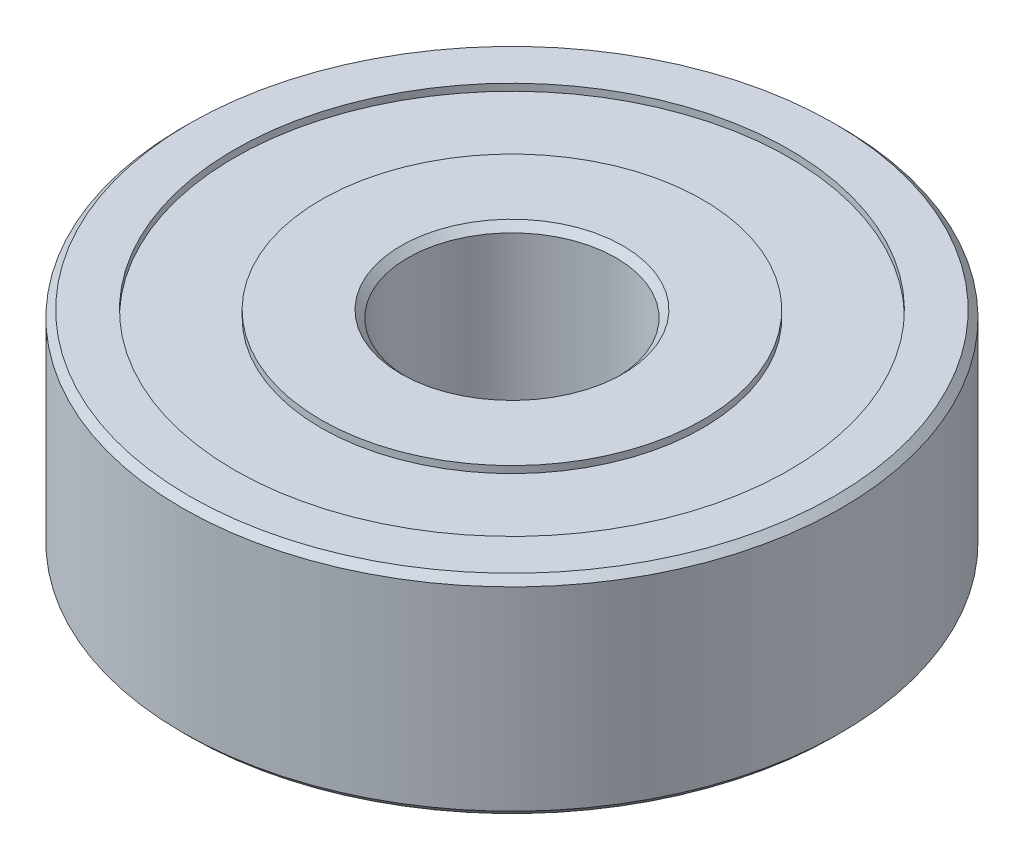
from build123d import *

# Parameters (mm, degrees)
SKETCH1_R           = 9.5
SKETCH1_R_2         = 3
BOSS_EXTRUDE1_DEPTH = 6
SKETCH2_R           = 8
SKETCH2_R_2         = 5.5
CUT_EXTRUDE1_DEPTH  = 0.2
SKETCH3_R           = 8
SKETCH3_R_2         = 5.5
CUT_EXTRUDE2_DEPTH  = 0.2
CHAMFER1_SIZE       = 0.2


with BuildPart() as part:
    # Sketch1 → Boss-Extrude1 (new body)
    with BuildSketch(Plane(origin=(0, 0, 0), x_dir=(1, 0, 0), z_dir=(0, 1, 0))):
        Circle(SKETCH1_R)
        Circle(SKETCH1_R_2, mode=Mode.SUBTRACT)
    extrude(amount=BOSS_EXTRUDE1_DEPTH)

    # Sketch2 → Cut-Extrude1 (cut)
    with BuildSketch(Plane(origin=(0, 6, 0), x_dir=(1, 0, 0), z_dir=(0, 1, 0))):
        Circle(SKETCH2_R)
        Circle(SKETCH2_R_2, mode=Mode.SUBTRACT)
    extrude(amount=-CUT_EXTRUDE1_DEPTH, mode=Mode.SUBTRACT)

    # Sketch3 → Cut-Extrude2 (cut)
    with BuildSketch(Plane.XZ):
        Circle(SKETCH3_R)
        Circle(SKETCH3_R_2, mode=Mode.SUBTRACT)
    extrude(amount=-CUT_EXTRUDE2_DEPTH, mode=Mode.SUBTRACT)

    # Chamfer1
    chamfer1_edges = [part.edges().sort_by_distance(p)[0] for p in [
        (-9.5, 0, 0),
        (-9.5, 6, 0),
        (-3, 0, 0),
        (-3, 6, 0),
    ]]
    chamfer(chamfer1_edges, length=CHAMFER1_SIZE)


solid = part.part
